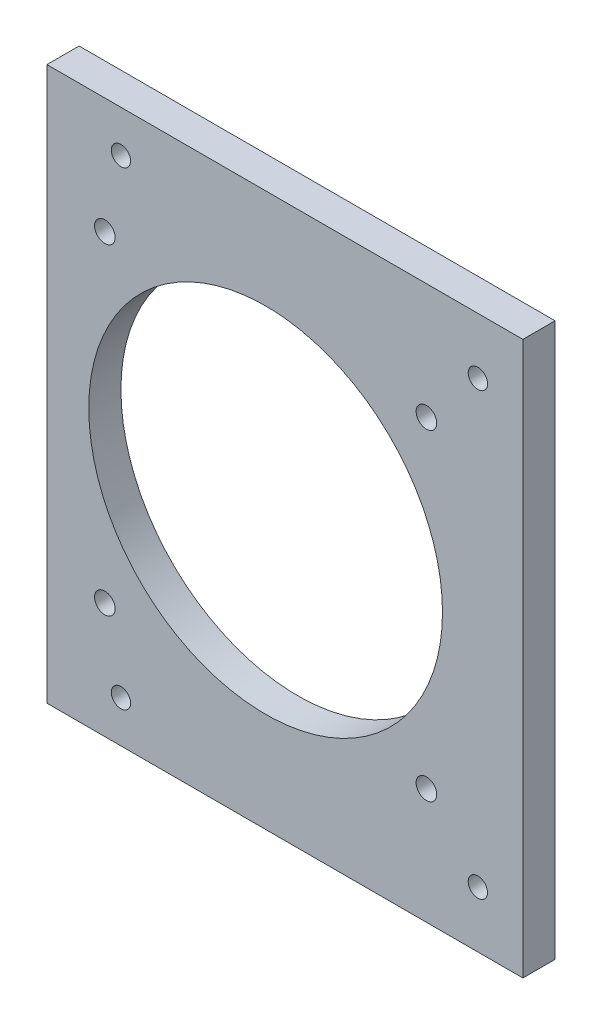
from build123d import *

# Parameters (mm, degrees)
SKETCH_1_W          = 69.5
SKETCH_1_H          = 100
SKETCH_1_R          = 1.5
EXTRUDE_1_DEPTH     = 5
SKETCH_5_R          = 1.6
SKETCH_5_R_2        = 27.5
CUT_EXTRUDE_1_DEPTH = 6
SKETCH_6_W          = 5
SKETCH_6_H          = 100
EXTRUDE_2_DEPTH     = 4.5
SKETCH_7_W          = 74
SKETCH_7_H          = 5
CUT_EXTRUDE_2_DEPTH = 7
SKETCH_8_W          = 74
SKETCH_8_H          = 5
CUT_EXTRUDE_3_DEPTH = 7


with BuildPart() as part:
    # Эскиз1 → Бобышка-Вытянуть1 (new body)
    with BuildSketch(Plane.XY.offset(81)):
        with Locations((-32.25, 45)):
            Rectangle(SKETCH_1_W, SKETCH_1_H)
        with Locations((-60, 8.5)):
            Circle(SKETCH_1_R, mode=Mode.SUBTRACT)
        with Locations((-60, 81.5)):
            Circle(SKETCH_1_R, mode=Mode.SUBTRACT)
        with Locations((-4.5, 79.25)):
            Circle(SKETCH_1_R, mode=Mode.SUBTRACT)
        with Locations((-4.5, 10.75)):
            Circle(SKETCH_1_R, mode=Mode.SUBTRACT)
    extrude(amount=-EXTRUDE_1_DEPTH)

    # Эскиз5 → Вырез-Вытянуть1 (cut, through all)
    with BuildSketch(Plane.XY.offset(81)):
        with Locations((-12.5, 70)):
            Circle(SKETCH_5_R)
        with Locations((-12.5, 20)):
            Circle(SKETCH_5_R)
        with Locations((-62.5, 20)):
            Circle(SKETCH_5_R)
        with Locations((-62.5, 70)):
            Circle(SKETCH_5_R)
        with Locations((-37.5, 45)):
            Circle(SKETCH_5_R_2)
    extrude(amount=-CUT_EXTRUDE_1_DEPTH, mode=Mode.SUBTRACT)

    # Эскиз6 → Бобышка-Вытянуть2 (add)
    with BuildSketch(Plane.ZY.offset(67)):
        with Locations((78.5, 45)):
            Rectangle(SKETCH_6_W, SKETCH_6_H)
    extrude(amount=EXTRUDE_2_DEPTH)

    # Эскиз7 → Вырез-Вытянуть2 (cut)
    with BuildSketch(Plane(origin=(0, 95, 0), x_dir=(1, 0, 0), z_dir=(0, 1, 0))):
        with Locations((-34.5, -78.5)):
            Rectangle(SKETCH_7_W, SKETCH_7_H)
    extrude(amount=-CUT_EXTRUDE_2_DEPTH, mode=Mode.SUBTRACT)

    # Эскиз8 → Вырез-Вытянуть3 (cut)
    with BuildSketch(Plane.XZ.offset(5)):
        with Locations((-34.5, 78.5)):
            Rectangle(SKETCH_8_W, SKETCH_8_H)
    extrude(amount=-CUT_EXTRUDE_3_DEPTH, mode=Mode.SUBTRACT)


solid = part.part
